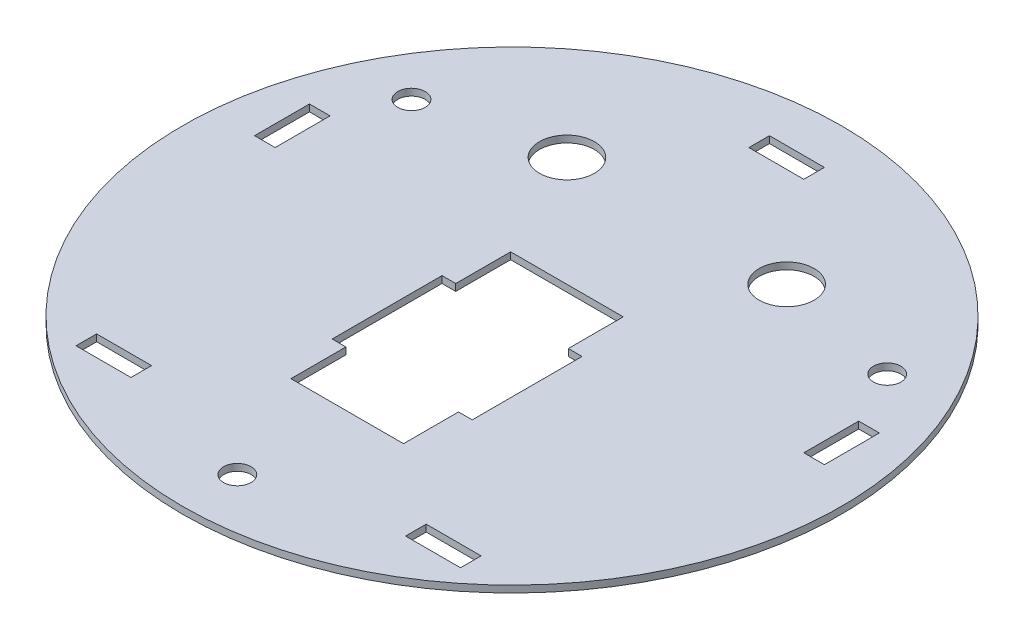
from build123d import *

# Parameters (mm, degrees)
SKETCH1_R           = 152.4
BOSS_EXTRUDE1_DEPTH = 3.175
SKETCH2_R           = 6.35
SKETCH2_R_2         = 12.7
SKETCH2_W           = 25.4
SKETCH2_H           = 9.525
SKETCH2_W_2         = 9.525
SKETCH2_H_2         = 25.4
CUT_EXTRUDE1_DEPTH  = 3.175


with BuildPart() as part:
    # Sketch1 → Boss-Extrude1 (new body)
    with BuildSketch(Plane(origin=(0, 0, 0), x_dir=(1, 0, 0), z_dir=(0, 1, 0))):
        with Locations(Location((152.4, 152.4, 0), (0, 0, 270))):  # turned: the seam where the file's is
            Circle(SKETCH1_R)
    extrude(amount=BOSS_EXTRUDE1_DEPTH)

    # Sketch2 → Cut-Extrude1 (cut)
    with BuildSketch(Plane(origin=(0, 3.175, 0), x_dir=(1, 0, 0), z_dir=(0, 1, 0))):
        with Locations(Location((42.414773719, 215.9, 0), (0, 0, 270))):  # turned: the seam where the file's is
            Circle(SKETCH2_R)
        with Locations(Location((152.4, 25.4, 0), (0, 0, 270))):  # turned: the seam where the file's is
            Circle(SKETCH2_R)
        with Locations(Location((262.385226281, 215.9, 0), (0, 0, 270))):  # turned: the seam where the file's is
            Circle(SKETCH2_R)
        with Locations(Location((101.6, 228.6, 0), (0, 0, 270))):  # turned: the seam where the file's is
            Circle(SKETCH2_R_2)
        with Locations(Location((203.2, 228.6, 0), (0, 0, 270))):  # turned: the seam where the file's is
            Circle(SKETCH2_R_2)
        with Locations((228.6, 44.45)):
            Rectangle(SKETCH2_W, SKETCH2_H)
        with Locations((76.2, 44.45)):
            Rectangle(SKETCH2_W, SKETCH2_H)
        Polygon((184.785, 101.612310097), (178.435, 101.612310097), (178.435, 76.2), (126.365, 76.2), (126.365, 101.612310097), (120.015, 101.612310097), (120.015, 152.412310097), (126.365, 152.412310097), (126.365, 177.8), (178.435, 177.8), (178.435, 152.412310097), (184.785, 152.412310097), align=None)
        with Locations((152.4, 279.4)):
            Rectangle(SKETCH2_W, SKETCH2_H)
        with Locations((279.4, 177.8)):
            Rectangle(SKETCH2_W_2, SKETCH2_H_2)
        with Locations((25.4, 177.8)):
            Rectangle(SKETCH2_W_2, SKETCH2_H_2)
    extrude(amount=-CUT_EXTRUDE1_DEPTH, mode=Mode.SUBTRACT)


solid = part.part
